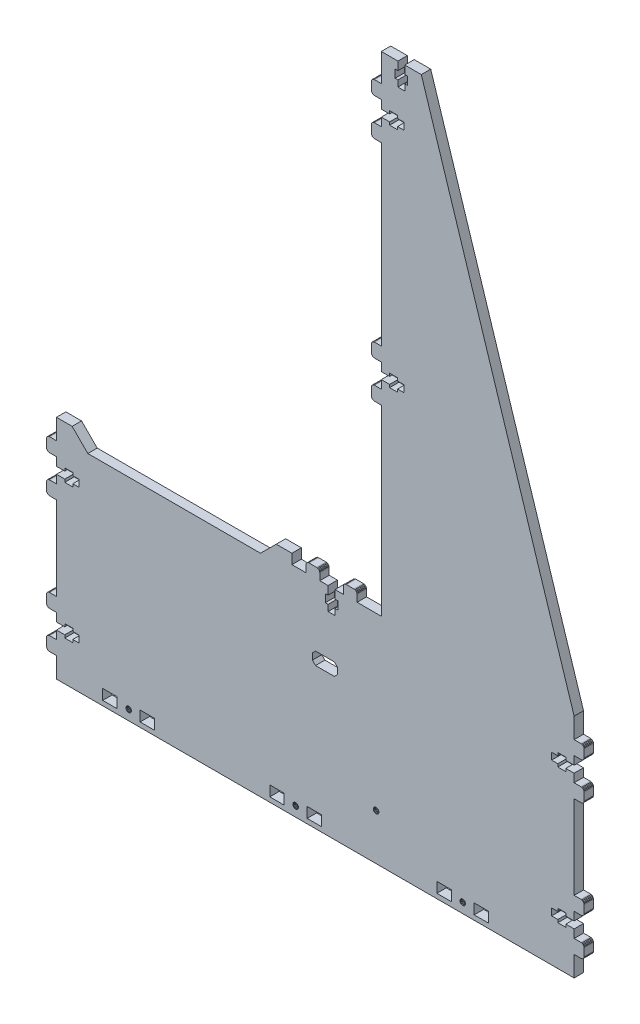
from build123d import *

# Parameters (mm, degrees)
SKETCH1_W           = 9.199995838
SKETCH1_H           = 6.600001918
SKETCH1_W_2         = 9.1999977
BOSS_EXTRUDE1_DEPTH = 6


with BuildPart() as part:
    # Sketch1 → Boss-Extrude1 (new body)
    with BuildSketch(Plane.XY):
        Polygon((22.621273296, 221.740971171), (22.621273296, 217.340966499), (18.671273474, 217.340966499), (18.671273474, 215.540968268), (13.571275709, 215.540968268), (13.571275709, 217.340966499), (8.271276887, 217.340966499), (8.271276887, 212.040969245), (3.971277391, 212.040969245), (3.453639301, 211.972820897), (2.971277391, 211.773020052), (2.557063829, 211.455182807), (2.239226584, 211.040969245), (2.039425739, 210.558607335), (1.971277391, 210.040969245), (1.971277391, 205.240974802), (2.039425739, 204.723336712), (2.239226584, 204.240974802), (2.557063829, 203.82676124), (2.971277391, 203.508923995), (3.453639301, 203.30912315), (3.971277391, 203.240974802), (8.271276887, 203.240974802), (8.271276887, 86.741009819), (-7.128720273, 86.741009819), (-7.128720273, 91.09100771), (-7.19686862, 91.608645801), (-7.396669465, 92.09100771), (-7.71450671, 92.505221273), (-8.128720273, 92.823058518), (-8.611082182, 93.022859363), (-9.128720273, 93.09100771), (-13.928714715, 93.09100771), (-14.446352805, 93.022859363), (-14.928714715, 92.823058518), (-15.342928277, 92.505221273), (-15.660765522, 92.09100771), (-15.860566367, 91.608645801), (-15.928714715, 91.09100771), (-15.928714715, 86.741009819), (-21.22871197, 86.741009819), (-21.22871197, 81.441010997), (-19.428713738, 81.441010997), (-19.428713738, 76.341013233), (-21.22871197, 76.341013233), (-21.22871197, 72.391013411), (-25.628716641, 72.391013411), (-25.628716641, 76.341013233), (-27.428714873, 76.341013233), (-27.428714873, 81.441010997), (-25.628716641, 81.441010997), (-25.628716641, 86.741009819), (-30.928708648, 86.741009819), (-30.928708648, 91.09100771), (-30.996856996, 91.608645801), (-31.196657841, 92.09100771), (-31.514495086, 92.505221273), (-31.928708648, 92.823058518), (-32.411070558, 93.022859363), (-32.928708648, 93.09100771), (-37.728704613, 93.09100771), (-38.246342703, 93.022859363), (-38.728704613, 92.823058518), (-39.142918176, 92.505221273), (-39.460755421, 92.09100771), (-39.660556266, 91.608645801), (-39.728704613, 91.09100771), (-39.728704613, 86.741009819), (-48.671976473, 86.741009819), (-48.671976473, 93.041009315), (-58.671975673, 93.041009315), (-68.671974873, 83.041010115), (-178.728658473, 83.041010115), (-188.728657673, 93.041009315), (-198.728656873, 93.041009315), (-198.728656873, 80.091008983), (-203.078654764, 80.091008983), (-203.596292854, 80.022860636), (-204.078654764, 79.823059791), (-204.492868326, 79.505222545), (-204.810705571, 79.091008983), (-205.010506416, 78.608647073), (-205.078654764, 78.091008983), (-205.078654764, 73.291013018), (-205.010506416, 72.773374928), (-204.810705571, 72.291013018), (-204.492868326, 71.876799456), (-204.078654764, 71.55896221), (-203.596292854, 71.359161365), (-203.078654764, 71.291013018), (-198.728656873, 71.291013018), (-198.728656873, 65.991021011), (-193.428658051, 65.991021011), (-193.428658051, 67.791019243), (-188.328660286, 67.791019243), (-188.328660286, 65.991021011), (-184.378660464, 65.991021011), (-184.378660464, 61.591016339), (-188.328660286, 61.591016339), (-188.328660286, 59.791018108), (-193.428658051, 59.791018108), (-193.428658051, 61.591016339), (-198.728656873, 61.591016339), (-198.728656873, 56.291019085), (-203.078654764, 56.291019085), (-203.596292854, 56.222870737), (-204.078654764, 56.023069892), (-204.492868326, 55.705232647), (-204.810705571, 55.291019085), (-205.010506416, 54.808657175), (-205.078654764, 54.291019085), (-205.078654764, 49.491024642), (-205.010506416, 48.973386552), (-204.810705571, 48.491024642), (-204.492868326, 48.07681108), (-204.078654764, 47.758973835), (-203.596292854, 47.55917299), (-203.078654764, 47.491024642), (-198.728656873, 47.491024642), (-198.728656873, -5.858987624), (-203.078654764, -5.858987624), (-203.596292854, -5.927135971), (-204.078654764, -6.126936816), (-204.492868326, -6.444774062), (-204.810705571, -6.858987624), (-205.010506416, -7.341349534), (-205.078654764, -7.858987624), (-205.078654764, -12.658983589), (-205.010506416, -13.176621679), (-204.810705571, -13.658983589), (-204.492868326, -14.073197151), (-204.078654764, -14.391034397), (-203.596292854, -14.590835242), (-203.078654764, -14.658983589), (-198.728656873, -14.658983589), (-198.728656873, -19.958975596), (-193.428658051, -19.958975596), (-193.428658051, -18.158977364), (-188.328660286, -18.158977364), (-188.328660286, -19.958975596), (-184.378660464, -19.958975596), (-184.378660464, -24.358980268), (-188.328660286, -24.358980268), (-188.328660286, -26.1589785), (-193.428658051, -26.1589785), (-193.428658051, -24.358980268), (-198.728656873, -24.358980268), (-198.728656873, -29.658977523), (-203.078654764, -29.658977523), (-203.596292854, -29.72712587), (-204.078654764, -29.926926715), (-204.492868326, -30.24476396), (-204.810705571, -30.658977523), (-205.010506416, -31.141339432), (-205.078654764, -31.658977523), (-205.078654764, -36.458971965), (-205.010506416, -36.976610055), (-204.810705571, -37.458971965), (-204.492868326, -37.873185527), (-204.078654764, -38.191022772), (-203.596292854, -38.390823617), (-203.078654764, -38.458971965), (-198.728656873, -38.458971965), (-198.728656873, -51.458971965), (131.171237559, -51.458971965), (131.171237559, -38.458971965), (135.521235451, -38.458971965), (136.038873541, -38.390823617), (136.521235451, -38.191022772), (136.935449013, -37.873185527), (137.253286258, -37.458971965), (137.453087103, -36.976610055), (137.521235451, -36.458971965), (137.521235451, -31.658976), (137.453087103, -31.141337909), (137.253286258, -30.658976), (136.935449013, -30.244762437), (136.521235451, -29.926925192), (136.038873541, -29.727124347), (135.521235451, -29.658976), (131.171237559, -29.658976), (131.171237559, -24.358983993), (125.871238738, -24.358983993), (125.871238738, -26.158982225), (120.771240973, -26.158982225), (120.771240973, -24.358983993), (116.821241151, -24.358983993), (116.821241151, -19.958979321), (120.771240973, -19.958979321), (120.771240973, -18.158981089), (125.871238738, -18.158981089), (125.871238738, -19.958979321), (131.171237559, -19.958979321), (131.171237559, -14.658982066), (135.521235451, -14.658982066), (136.038873541, -14.590833719), (136.521235451, -14.391032874), (136.935449013, -14.073195629), (137.253286258, -13.658982066), (137.453087103, -13.176620156), (137.521235451, -12.658982066), (137.521235451, -7.858987624), (137.453087103, -7.341349534), (137.253286258, -6.858987624), (136.935449013, -6.444774062), (136.521235451, -6.126936816), (136.038873541, -5.927135971), (135.521235451, -5.858987624), (131.171237559, -5.858987624), (131.171237559, 47.491028368), (135.521235451, 47.491028368), (136.038873541, 47.559176715), (136.521235451, 47.75897756), (136.935449013, 48.076814805), (137.253286258, 48.491028368), (137.453087103, 48.973390277), (137.521235451, 49.491028368), (137.521235451, 54.291024333), (137.453087103, 54.808662423), (137.253286258, 55.291024333), (136.935449013, 55.705237895), (136.521235451, 56.02307514), (136.038873541, 56.222875985), (135.521235451, 56.291024333), (131.171237559, 56.291024333), (131.171237559, 61.591016339), (125.871238738, 61.591016339), (125.871238738, 59.791018108), (120.771240973, 59.791018108), (120.771240973, 61.591016339), (116.821241151, 61.591016339), (116.821241151, 65.991021011), (120.771240973, 65.991021011), (120.771240973, 67.791019243), (125.871238738, 67.791019243), (125.871238738, 65.991021011), (131.171237559, 65.991021011), (131.171237559, 71.291018266), (135.521235451, 71.291018266), (136.038873541, 71.359166613), (136.521235451, 71.558967458), (136.935449013, 71.876804704), (137.253286258, 72.291018266), (137.453087103, 72.773380176), (137.521235451, 73.291018266), (137.521235451, 78.091012708), (137.453087103, 78.608650798), (137.253286258, 79.091012708), (136.935449013, 79.505226271), (136.521235451, 79.823063516), (136.038873541, 80.022864361), (135.521235451, 80.091012708), (131.171237559, 80.091012708), (131.171237559, 93.041009315), (33.779567873, 398.440911587), (23.271275127, 398.440911587), (23.271275127, 393.140912766), (25.071273359, 393.140912766), (25.071273359, 388.040915001), (23.271275127, 388.040915001), (23.271275127, 384.090915179), (18.871270456, 384.090915179), (18.871270456, 388.040915001), (17.071272224, 388.040915001), (17.071272224, 393.140912766), (18.871270456, 393.140912766), (18.871270456, 398.440911587), (8.271276887, 398.440911587), (8.271276887, 380.708271855), (3.971277391, 380.708271855), (3.453639301, 380.640123508), (2.971277391, 380.440322663), (2.557063829, 380.122485417), (2.239226584, 379.708271855), (2.039425739, 379.225909945), (1.971277391, 378.708271855), (1.971277391, 373.90827589), (2.039425739, 373.3906378), (2.239226584, 372.90827589), (2.557063829, 372.494062327), (2.971277391, 372.176225082), (3.453639301, 371.976424237), (3.971277391, 371.90827589), (8.271276887, 371.90827589), (8.271276887, 366.608283883), (13.571275709, 366.608283883), (13.571275709, 368.408282115), (18.671273474, 368.408282115), (18.671273474, 366.608283883), (22.621273296, 366.608283883), (22.621273296, 362.208279211), (18.671273474, 362.208279211), (18.671273474, 360.408280979), (13.571275709, 360.408280979), (13.571275709, 362.208279211), (8.271276887, 362.208279211), (8.271276887, 356.908281956), (3.971277391, 356.908281956), (3.453639301, 356.840133609), (2.971277391, 356.640332764), (2.557063829, 356.322495519), (2.239226584, 355.908281956), (2.039425739, 355.425920047), (1.971277391, 354.908281956), (1.971277391, 350.108287514), (2.039425739, 349.590649424), (2.239226584, 349.108287514), (2.557063829, 348.694073952), (2.971277391, 348.376236707), (3.453639301, 348.176435862), (3.971277391, 348.108287514), (8.271276887, 348.108287514), (8.271276887, 235.840959143), (3.971277391, 235.840959143), (3.453639301, 235.772810796), (2.971277391, 235.573009951), (2.557063829, 235.255172705), (2.239226584, 234.840959143), (2.039425739, 234.358597233), (1.971277391, 233.840959143), (1.971277391, 229.040963178), (2.039425739, 228.523325088), (2.239226584, 228.040963178), (2.557063829, 227.626749616), (2.971277391, 227.30891237), (3.453639301, 227.109111525), (3.971277391, 227.040963178), (8.271276887, 227.040963178), (8.271276887, 221.740971171), (13.571275709, 221.740971171), (13.571275709, 223.540969403), (18.671273474, 223.540969403), (18.671273474, 221.740971171), align=None)
        Polygon((-48.019038574, -45.625294781), (-48.080430872, -45.158973981), (-48.019038574, -44.692653181), (-47.839045464, -44.258111373), (-47.552717774, -43.884961863), (-47.179568264, -43.598634173), (-46.745026456, -43.418641063), (-46.278705657, -43.357248765), (-45.812384857, -43.418641063), (-45.377843049, -43.598634173), (-45.004693539, -43.884961863), (-44.718365849, -44.258111373), (-44.538372739, -44.692653181), (-44.476980441, -45.158973981), (-44.538372739, -45.625294781), (-44.718365849, -46.059836588), (-45.004693539, -46.432986098), (-45.377843049, -46.719313788), (-45.812384857, -46.899306898), (-46.278705657, -46.960699196), (-46.745026456, -46.899306898), (-47.179568264, -46.719313788), (-47.552717774, -46.432986098), (-47.839045464, -46.059836588), align=None, mode=Mode.SUBTRACT)
        Polygon((61.731600087, -46.059836588), (61.445272397, -46.432986098), (61.072122887, -46.719313788), (60.637581079, -46.899306898), (60.171260279, -46.960699196), (59.70493948, -46.899306898), (59.270397672, -46.719313788), (58.897248162, -46.432986098), (58.610920472, -46.059836588), (58.430927362, -45.625294781), (58.369535064, -45.158973981), (58.430927362, -44.692653181), (58.610920472, -44.258111373), (58.897248162, -43.884961863), (59.270397672, -43.598634173), (59.70493948, -43.418641063), (60.171260279, -43.357248765), (60.637581079, -43.418641063), (61.072122887, -43.598634173), (61.445272397, -43.884961863), (61.731600087, -44.258111373), (61.911593197, -44.692653181), (61.972985495, -45.158973981), (61.911593197, -45.625294781), align=None, mode=Mode.SUBTRACT)
        with Locations((-58.178701707, -45.15897302)):
            Rectangle(SKETCH1_W, SKETCH1_H, mode=Mode.SUBTRACT)
        with Locations((48.271264229, -45.15897302)):
            Rectangle(SKETCH1_W, SKETCH1_H, mode=Mode.SUBTRACT)
        with Locations((72.071255059, -45.15897302)):
            Rectangle(SKETCH1_W_2, SKETCH1_H, mode=Mode.SUBTRACT)
        Polygon((-151.827808985, -46.719313788), (-152.262350793, -46.899306898), (-152.728671593, -46.960699196), (-153.194992392, -46.899306898), (-153.6295342, -46.719313788), (-154.00268371, -46.432986098), (-154.2890114, -46.059836588), (-154.46900451, -45.625294781), (-154.530396808, -45.158973981), (-154.46900451, -44.692653181), (-154.2890114, -44.258111373), (-154.00268371, -43.884961863), (-153.6295342, -43.598634173), (-153.194992392, -43.418641063), (-152.728671593, -43.357248765), (-152.262350793, -43.418641063), (-151.827808985, -43.598634173), (-151.454659475, -43.884961863), (-151.168331785, -44.258111373), (-150.988338675, -44.692653181), (-150.926946377, -45.158973981), (-150.988338675, -45.625294781), (-151.168331785, -46.059836588), (-151.454659475, -46.432986098), align=None, mode=Mode.SUBTRACT)
        with Locations((-140.828676813, -45.15897302)):
            Rectangle(SKETCH1_W_2, SKETCH1_H, mode=Mode.SUBTRACT)
        with Locations((-164.628667643, -45.15897302)):
            Rectangle(SKETCH1_W, SKETCH1_H, mode=Mode.SUBTRACT)
        with Locations((-34.378710877, -45.15897302)):
            Rectangle(SKETCH1_W_2, SKETCH1_H, mode=Mode.SUBTRACT)
        Polygon((6.771276887, -22.158981657), (6.709943375, -22.624855938), (6.530122614, -23.058981657), (6.244069094, -23.431773863), (5.871276887, -23.717827384), (5.437151169, -23.897648144), (4.971276887, -23.958981657), (4.505402606, -23.897648144), (4.071276887, -23.717827384), (3.698484681, -23.431773863), (3.412431161, -23.058981657), (3.2326104, -22.624855938), (3.171276887, -22.158981657), (3.2326104, -21.693107376), (3.412431161, -21.258981657), (3.698484681, -20.886189451), (4.071276887, -20.60013593), (4.505402606, -20.42031517), (4.971276887, -20.358981657), (5.437151169, -20.42031517), (5.871276887, -20.60013593), (6.244069094, -20.886189451), (6.530122614, -21.258981657), (6.709943375, -21.693107376), align=None, mode=Mode.SUBTRACT)
        Polygon((-19.630740813, 44.577844561), (-21.630740813, 46.577844561), (-33.626705412, 46.577844561), (-35.626705412, 44.577844561), (-35.626705412, 40.577847121), (-33.626705412, 38.577847121), (-21.630740813, 38.577847121), (-19.630740813, 40.577847121), align=None, mode=Mode.SUBTRACT)
    extrude(amount=BOSS_EXTRUDE1_DEPTH)


solid = part.part
